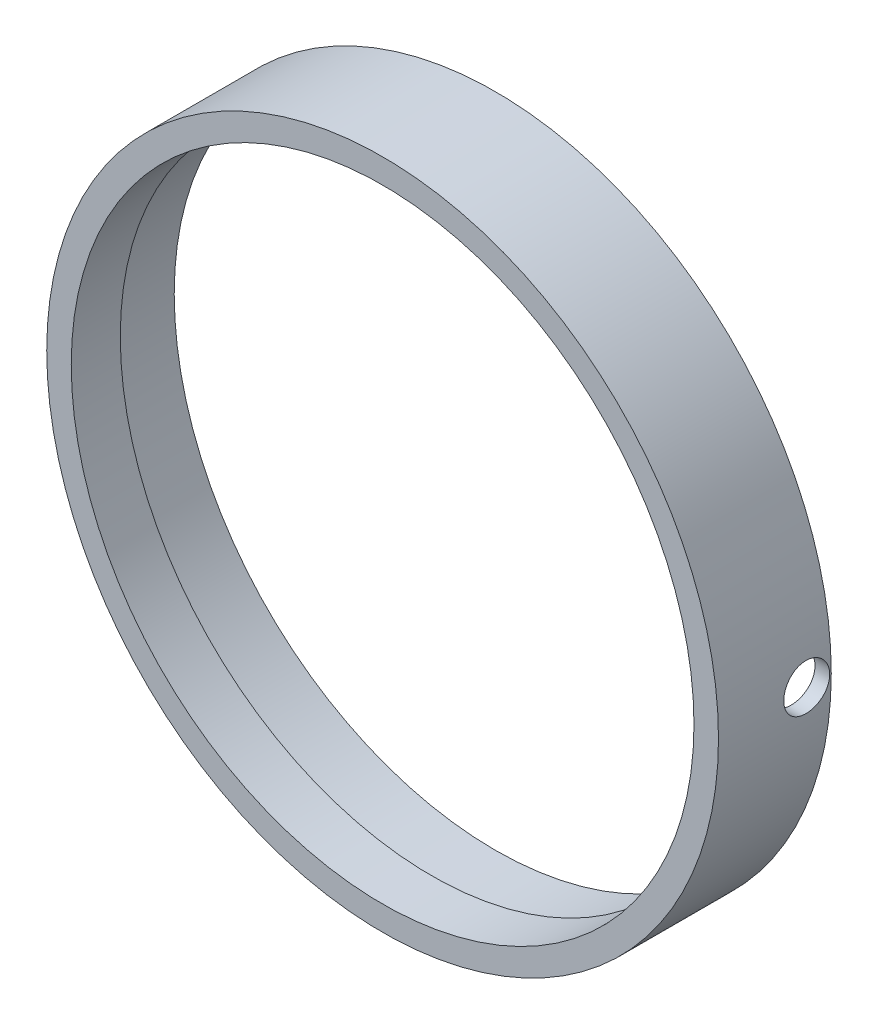
from build123d import *

# Parameters (mm, degrees)
SKETCH1_R                          = 34.798
SKETCH1_R_2                        = 32.258
BOSS_EXTRUDE1_DEPTH                = 11.684
F_3_16_0_1875_DIAMETER_HOLE1_D     = 4.7625
F_3_16_0_1875_DIAMETER_HOLE1_DEPTH = 54.102
F_3_16_0_1875_DIAMETER_HOLE1_TIP   = 1.430799349
SKETCH3_R                          = 33.274
SKETCH3_R_2                        = 32.258
CUT_EXTRUDE1_DEPTH                 = 6.604


with BuildPart() as part:
    # Sketch1 → Boss-Extrude1 (new body)
    with BuildSketch(Plane.XY):
        Circle(SKETCH1_R)
        Circle(SKETCH1_R_2, mode=Mode.SUBTRACT)
    extrude(amount=BOSS_EXTRUDE1_DEPTH)

    # 3/16 (0.1875) Diameter Hole1
    with Locations(Plane(origin=(34.798, 0, 2.54), x_dir=(0, 1, 0), z_dir=(1, 0, 0))):
        with Locations((0, 0)):
            Hole(F_3_16_0_1875_DIAMETER_HOLE1_D / 2, depth=F_3_16_0_1875_DIAMETER_HOLE1_DEPTH)
            with Locations((0, 0, -(F_3_16_0_1875_DIAMETER_HOLE1_DEPTH + F_3_16_0_1875_DIAMETER_HOLE1_TIP / 2))):  # 118° drill point
                Cone(0, F_3_16_0_1875_DIAMETER_HOLE1_D / 2, F_3_16_0_1875_DIAMETER_HOLE1_TIP, mode=Mode.SUBTRACT)

    # Sketch3 → Cut-Extrude1 (cut)
    with BuildSketch(Plane(origin=(0, 0, 0), x_dir=(-1, 0, 0), z_dir=(0, 0, -1))):
        Circle(SKETCH3_R)
        Circle(SKETCH3_R_2, mode=Mode.SUBTRACT)
    extrude(amount=-CUT_EXTRUDE1_DEPTH, mode=Mode.SUBTRACT)


solid = part.part
